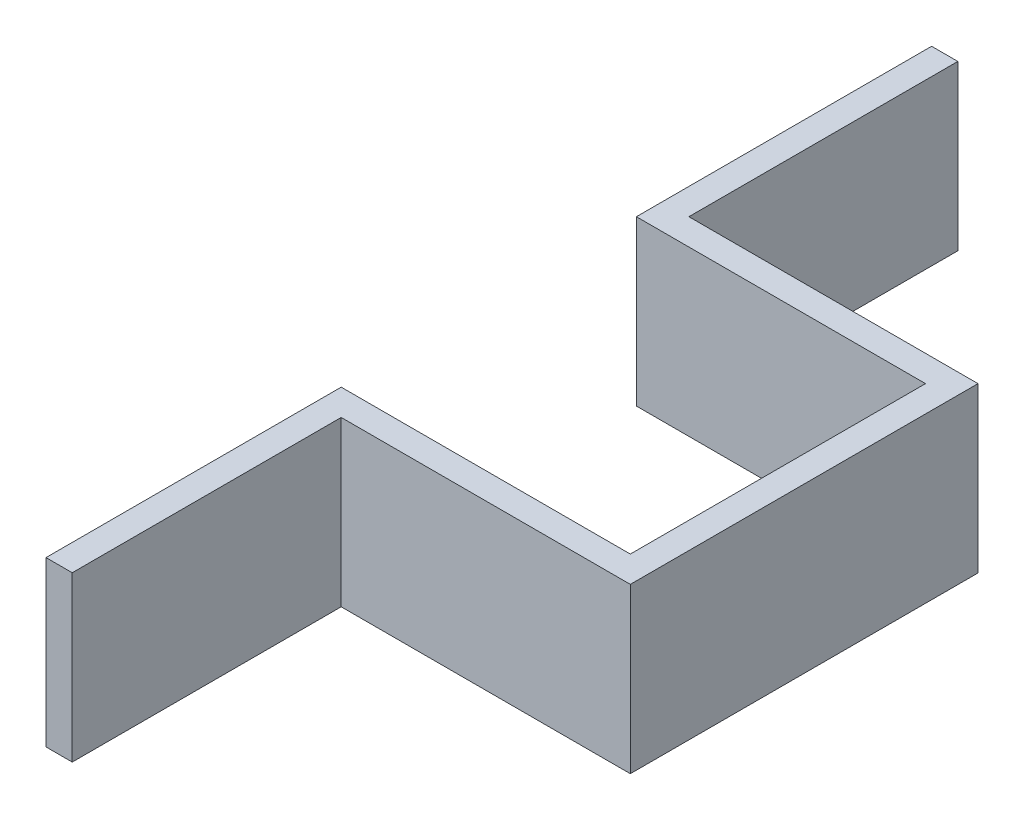
from build123d import *

# Parameters (mm, degrees)
BOSS_EXTRUDE1_DEPTH = 25


with BuildPart() as part:
    # Sketch1 → Boss-Extrude1 (new body)
    with BuildSketch(Plane(origin=(0, 5, 0), x_dir=(1, 0, 0), z_dir=(0, 1, 0))):
        Polygon((194.102258895, 302.5), (190.102258895, 302.5), (190.102258895, 257.5), (234.174494692, 257.5), (234.174494692, 212.5), (190.102258895, 212.5), (190.102258895, 167.5), (194.102258895, 167.5), (194.102258895, 208.5), (238.174494692, 208.5), (238.174494692, 261.5), (194.102258895, 261.5), align=None)
    extrude(amount=-BOSS_EXTRUDE1_DEPTH)


solid = part.part
